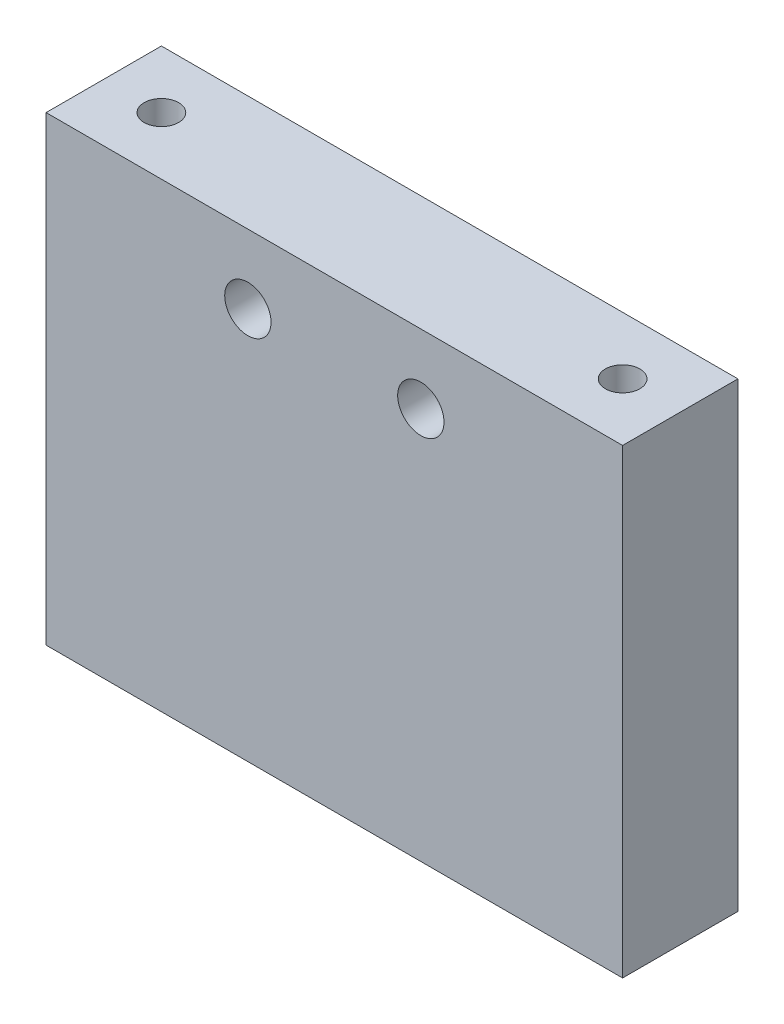
from build123d import *

# Parameters (mm, degrees)
SKETCH1_W                        = 63.5
SKETCH1_H                        = 12.7
BOSS_EXTRUDE1_DEPTH              = 50.8
F_25_0_1495_DIAMETER_HOLE1_D     = 3.7973
F_25_0_1495_DIAMETER_HOLE1_DEPTH = 12.7
F_25_0_1495_DIAMETER_HOLE1_TIP   = 1.140824014
F_7_0_201_DIAMETER_HOLE1_D       = 5.1054
F_7_0_201_DIAMETER_HOLE1_DEPTH   = 12.7
F_7_0_201_DIAMETER_HOLE1_TIP     = 1.533816902


with BuildPart() as part:
    # Sketch1 → Boss-Extrude1 (new body)
    with BuildSketch(Plane(origin=(0, 0, 0), x_dir=(1, 0, 0), z_dir=(0, 1, 0))):
        with Locations((31.75, 6.35)):
            Rectangle(SKETCH1_W, SKETCH1_H)
    extrude(amount=BOSS_EXTRUDE1_DEPTH)

    # #25 (0.1495) Diameter Hole1
    with Locations(Plane(origin=(0, 50.8, 0), x_dir=(1, 0, 0), z_dir=(0, 1, 0))):
        with Locations((6.35, 6.35), (57.15, 6.35)):
            Hole(F_25_0_1495_DIAMETER_HOLE1_D / 2, depth=F_25_0_1495_DIAMETER_HOLE1_DEPTH)
            with Locations((0, 0, -(F_25_0_1495_DIAMETER_HOLE1_DEPTH + F_25_0_1495_DIAMETER_HOLE1_TIP / 2))):  # 118° drill point
                Cone(0, F_25_0_1495_DIAMETER_HOLE1_D / 2, F_25_0_1495_DIAMETER_HOLE1_TIP, mode=Mode.SUBTRACT)

    # #7 (0.201) Diameter Hole1
    with Locations(Plane(origin=(0, 0, -12.7), x_dir=(-1, 0, 0), z_dir=(0, 0, -1))):
        with Locations((-22.225, 43.18), (-41.275, 43.18)):
            Hole(F_7_0_201_DIAMETER_HOLE1_D / 2, depth=F_7_0_201_DIAMETER_HOLE1_DEPTH)
            with Locations((0, 0, -(F_7_0_201_DIAMETER_HOLE1_DEPTH + F_7_0_201_DIAMETER_HOLE1_TIP / 2))):  # 118° drill point
                Cone(0, F_7_0_201_DIAMETER_HOLE1_D / 2, F_7_0_201_DIAMETER_HOLE1_TIP, mode=Mode.SUBTRACT)


solid = part.part
